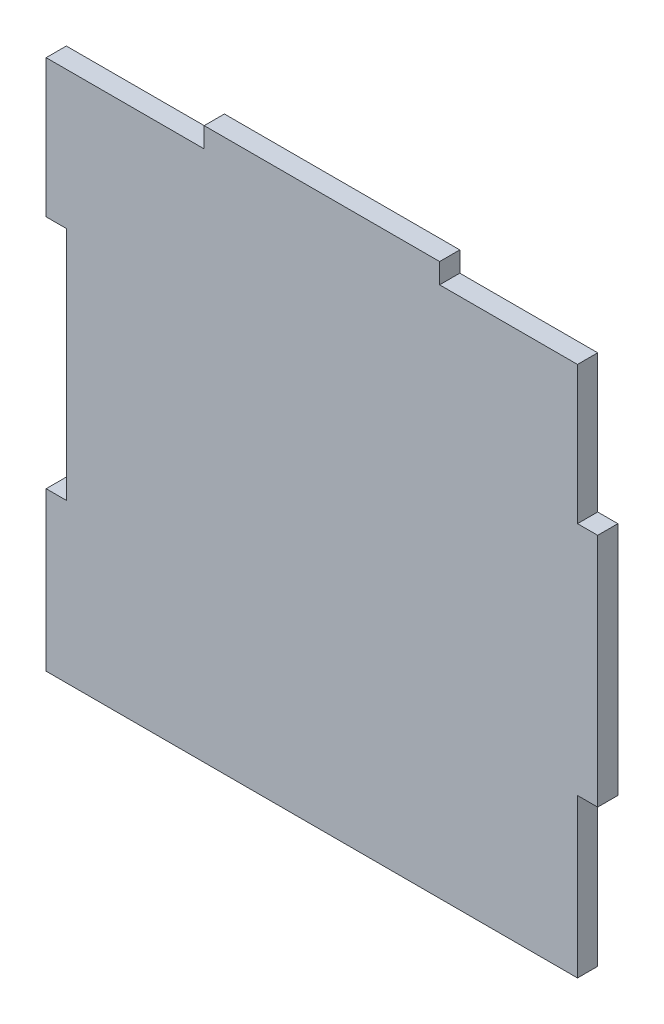
from build123d import *

# Parameters (mm, degrees)
BOSS_EXTRUDE1_DEPTH = 3


with BuildPart() as part:
    # Sketch1 → Boss-Extrude1 (new body)
    with BuildSketch(Plane.XY):
        Polygon((-38, 39.5), (-17.5, 39.5), (-17.5, 42.5), (17.5, 42.5), (17.5, 39.5), (38, 39.5), (38, 19), (41, 19), (41, 16), (41, -16), (38, -16), (38, -19), (38, -39.5), (-41, -39.5), (-41, -19), (-41, -16), (-38, -16), (-38, 16), (-38, 19), (-41, 19), (-41, 39.5), align=None)
    extrude(amount=BOSS_EXTRUDE1_DEPTH)


solid = part.part
